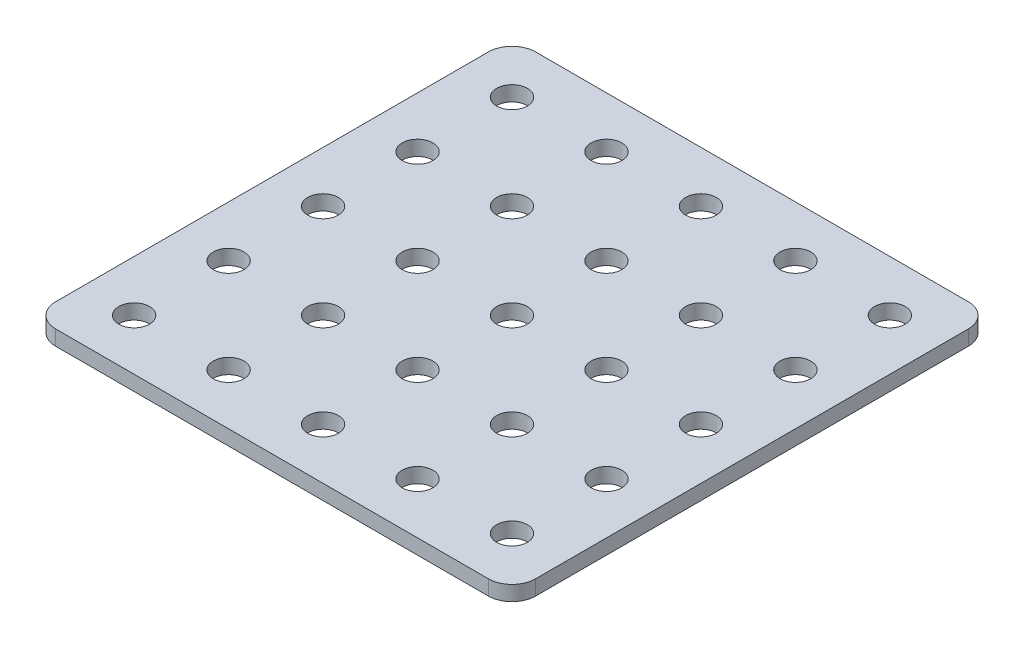
from build123d import *

# Parameters (mm, degrees)
SKETCH1_W           = 101.6
SKETCH1_H           = 101.6
BOSS_EXTRUDE1_DEPTH = 3.175
FILLET1_R           = 5
SKETCH2_R           = 3.25
CUT_EXTRUDE1_DEPTH  = 3.175
LPATTERN1_COUNT     = 3
LPATTERN1_PITCH     = 20
LPATTERN2_COUNT     = 3
LPATTERN2_PITCH     = 20


with BuildPart() as part:
    # Sketch1 → Boss-Extrude1 (new body)
    with BuildSketch(Plane(origin=(0, 0, 0), x_dir=(1, 0, 0), z_dir=(0, 1, 0))):
        Rectangle(SKETCH1_W, SKETCH1_H)
    extrude(amount=BOSS_EXTRUDE1_DEPTH)

    # Fillet1
    fillet1_edges = [part.edges().sort_by_distance(p)[0] for p in [
        (50.8, 1.5875, 50.8),
        (-50.8, 1.5875, 50.8),
        (-50.8, 1.5875, -50.8),
        (50.8, 1.5875, -50.8),
    ]]
    fillet(fillet1_edges, radius=FILLET1_R)

    # Sketch2 → Cut-Extrude1 (cut)
    with BuildSketch(Plane(origin=(0, 3.175, 0), x_dir=(1, 0, 0), z_dir=(0, 1, 0))):
        Circle(SKETCH2_R)
        with Locations((20, 0)):
            Circle(SKETCH2_R)
        with Locations((40, 0)):
            Circle(SKETCH2_R)
        with Locations((-20, 0)):
            Circle(SKETCH2_R)
        with Locations((-40, 0)):
            Circle(SKETCH2_R)
    cut_extrude1 = extrude(amount=-CUT_EXTRUDE1_DEPTH, mode=Mode.SUBTRACT)

    # LPattern1: Cut-Extrude1 ×3
    with Locations(*[(0, 0, i * LPATTERN1_PITCH) for i in range(1, LPATTERN1_COUNT)]):
        add(cut_extrude1, mode=Mode.SUBTRACT)

    # LPattern2: Cut-Extrude1 ×3
    with Locations(*[(0, 0, -i * LPATTERN2_PITCH) for i in range(1, LPATTERN2_COUNT)]):
        add(cut_extrude1, mode=Mode.SUBTRACT)


solid = part.part
